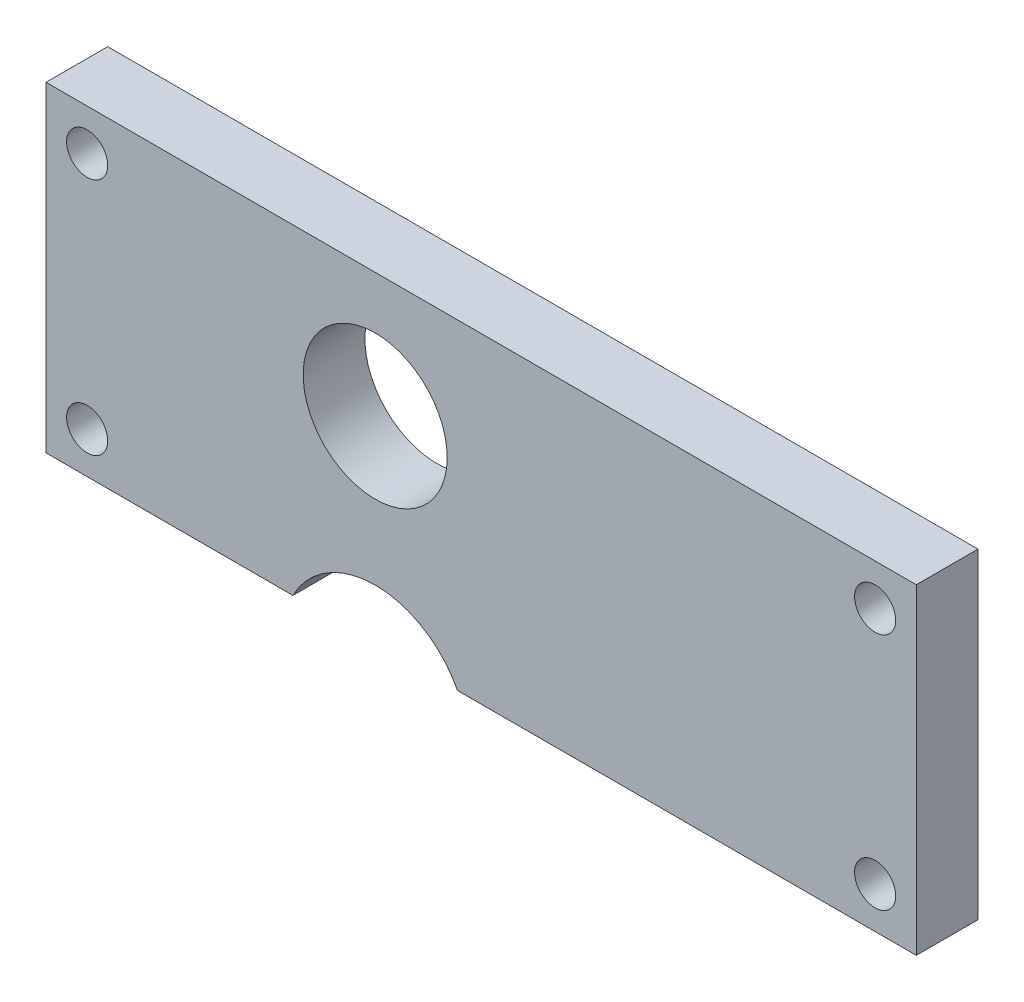
from build123d import *

# Parameters (mm, degrees)
SKETCH1_W           = 42.3
SKETCH1_H           = 15.6
BOSS_EXTRUDE1_DEPTH = 3
SKETCH2_R           = 1
CUT_EXTRUDE1_DEPTH  = 4
SKETCH3_R           = 3.5
CUT_EXTRUDE2_DEPTH  = 4
CUT_EXTRUDE3_DEPTH  = 4


with BuildPart() as part:
    # Sketch1 → Boss-Extrude1 (new body)
    with BuildSketch(Plane.XY):
        with Locations((21.15, 7.8)):
            Rectangle(SKETCH1_W, SKETCH1_H)
    extrude(amount=BOSS_EXTRUDE1_DEPTH)

    # Sketch2 → Cut-Extrude1 (cut, through all)
    with BuildSketch(Plane.XY.offset(3)):
        with Locations((2, 13.6)):
            Circle(SKETCH2_R)
        with Locations((40.3, 13.6)):
            Circle(SKETCH2_R)
        with Locations((40.3, 2)):
            Circle(SKETCH2_R)
        with Locations((2, 2)):
            Circle(SKETCH2_R)
    extrude(amount=-CUT_EXTRUDE1_DEPTH, mode=Mode.SUBTRACT)

    # Sketch3 → Cut-Extrude2 (cut, through all)
    with BuildSketch(Plane.XY.offset(3)):
        with Locations((16, 9.55)):
            Circle(SKETCH3_R)
    extrude(amount=-CUT_EXTRUDE2_DEPTH, mode=Mode.SUBTRACT)

    # Sketch4 → Cut-Extrude3 (cut, through all)
    with BuildSketch(Plane.XY.offset(3)):
        with BuildLine():
            Line((12, 0), (20, 0))
            ThreePointArc((20, 0), (16, 2.438447187), (12, 0))
        make_face()
    extrude(amount=-CUT_EXTRUDE3_DEPTH, mode=Mode.SUBTRACT)


solid = part.part
